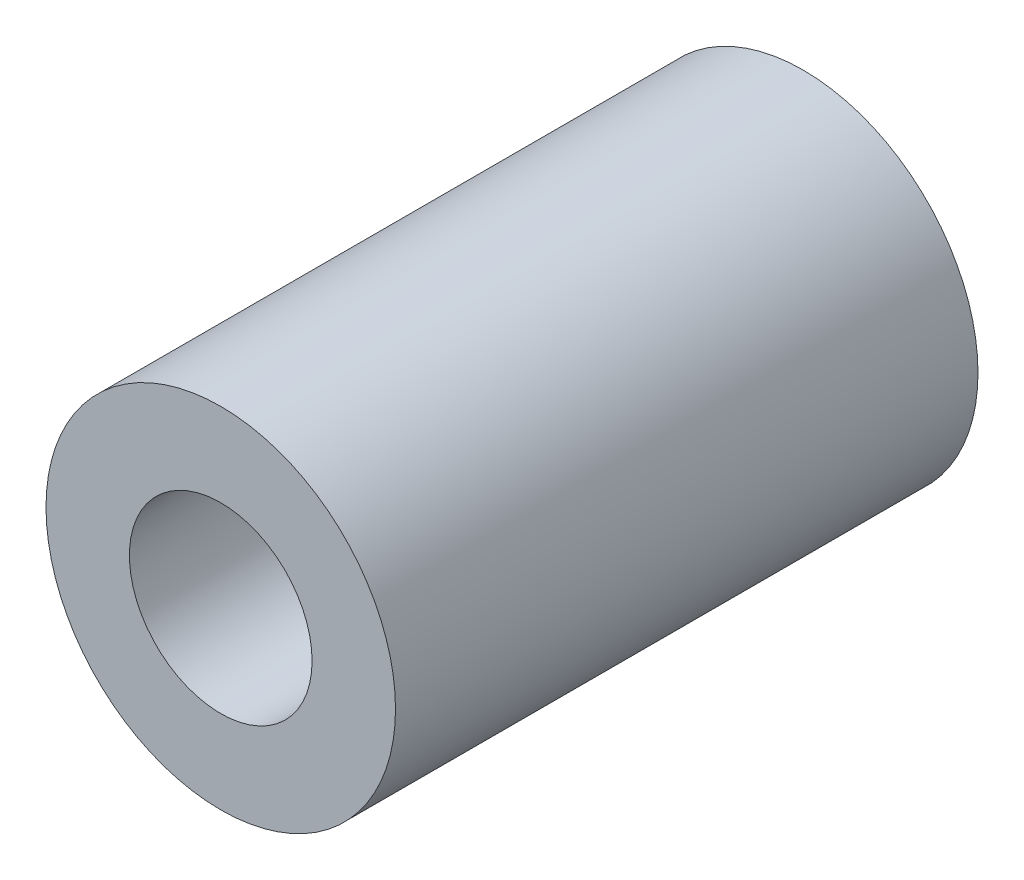
from build123d import *

# Parameters (mm, degrees)
SKETCH1_R           = 4.7625
SKETCH1_R_2         = 2.4892
BOSS_EXTRUDE1_DEPTH = 15.875


with BuildPart() as part:
    # Sketch1 → Boss-Extrude1 (new body)
    with BuildSketch(Plane.XY):
        Circle(SKETCH1_R)
        Circle(SKETCH1_R_2, mode=Mode.SUBTRACT)
    extrude(amount=BOSS_EXTRUDE1_DEPTH)


solid = part.part
